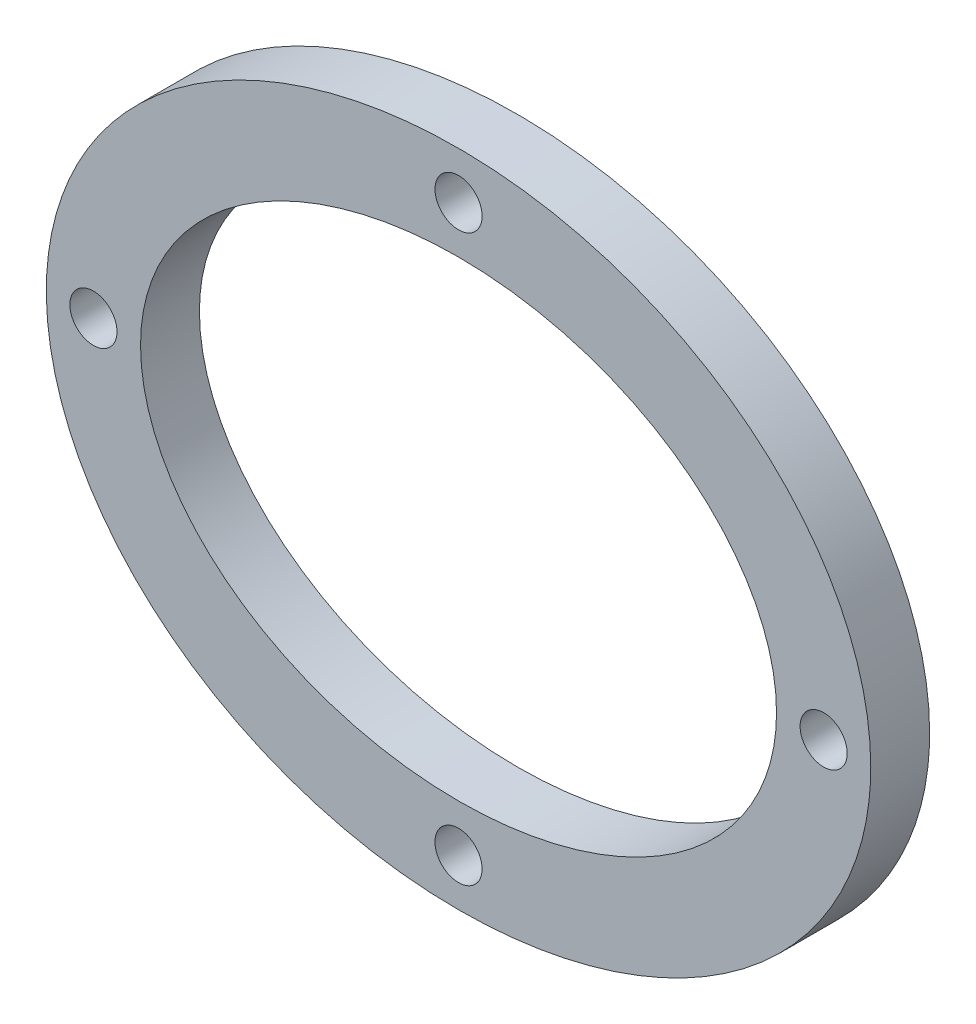
from build123d import *

# Parameters (mm, degrees)
ESQUISSE1_RX            = 35
ESQUISSE1_RY            = 28
ESQUISSE1_RX_2          = 27
ESQUISSE1_RY_2          = 20
BOSS_EXTRU_1_DEPTH      = 5
ESQUISSE2_R             = 2
ENL_V_MAT_EXTRU_1_DEPTH = 5


with BuildPart() as part:
    # Esquisse1 → Boss.-Extru.1 (new body)
    with BuildSketch(Plane.XY):
        with Locations((0, 0)):
            Ellipse(ESQUISSE1_RX, ESQUISSE1_RY)
        with Locations((0, 0)):
            Ellipse(ESQUISSE1_RX_2, ESQUISSE1_RY_2, mode=Mode.SUBTRACT)
    extrude(amount=BOSS_EXTRU_1_DEPTH)

    # Esquisse2 → Enlèv. mat.-Extru.1 (cut)
    with BuildSketch(Plane.XY.offset(5)):
        with Locations((-31, 0)):
            Circle(ESQUISSE2_R)
        with Locations((0, 24)):
            Circle(ESQUISSE2_R)
        with Locations((31, 0)):
            Circle(ESQUISSE2_R)
        with Locations((0, -24)):
            Circle(ESQUISSE2_R)
    extrude(amount=-ENL_V_MAT_EXTRU_1_DEPTH, mode=Mode.SUBTRACT)


solid = part.part
